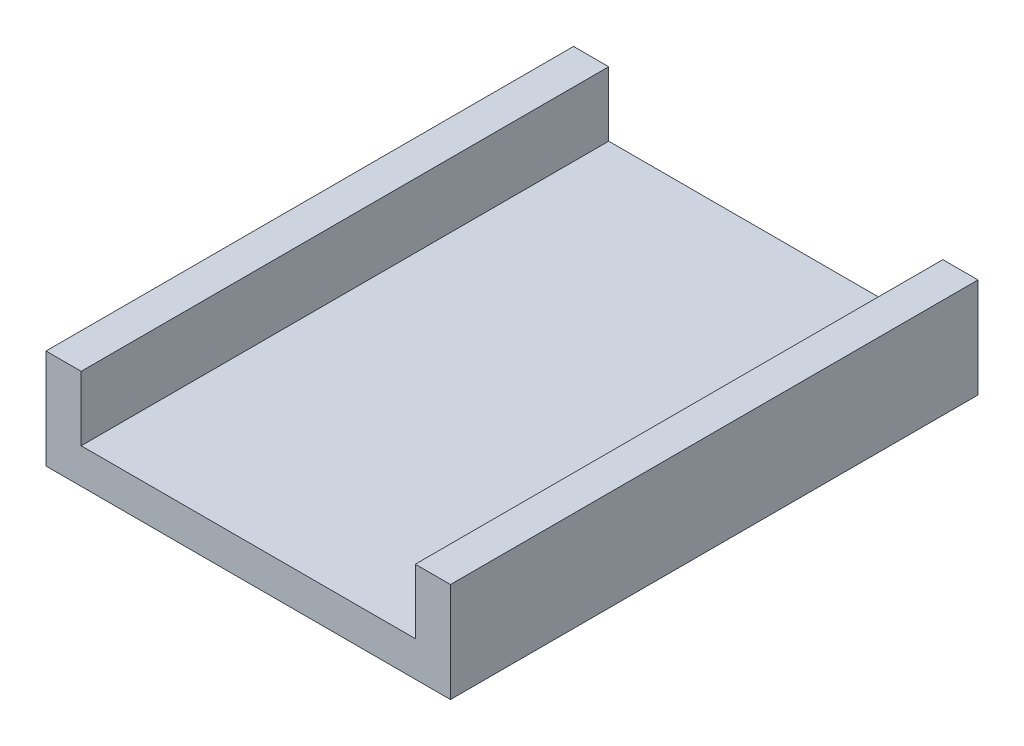
from build123d import *

# Parameters (mm, degrees)
SKETCH2_W           = 34.5
SKETCH2_H           = 45
BOSS_EXTRUDE1_DEPTH = 3
SKETCH3_W           = 3
SKETCH3_H           = 45
BOSS_EXTRUDE2_DEPTH = 5.5


with BuildPart() as part:
    # Sketch2 → Boss-Extrude1 (new body)
    with BuildSketch(Plane(origin=(0, 0, 0), x_dir=(1, 0, 0), z_dir=(0, 1, 0))):
        Rectangle(SKETCH2_W, SKETCH2_H)
    extrude(amount=BOSS_EXTRUDE1_DEPTH)

    # Sketch3 → Boss-Extrude2 (add)
    with BuildSketch(Plane(origin=(0, 3, 0), x_dir=(1, 0, 0), z_dir=(0, 1, 0))):
        with Locations((-15.75, 0)):
            Rectangle(SKETCH3_W, SKETCH3_H)
        with Locations((15.75, 0)):
            Rectangle(SKETCH3_W, SKETCH3_H)
    extrude(amount=BOSS_EXTRUDE2_DEPTH)


solid = part.part
